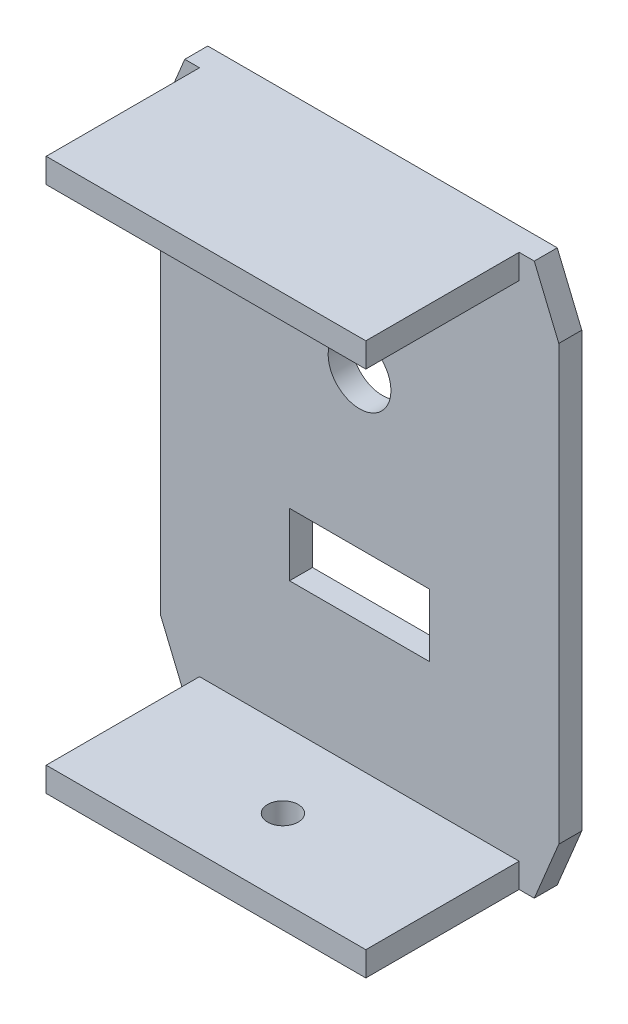
from build123d import *

# Parameters (mm, degrees)
BOSS_EXTRUDE1_DEPTH = 4.7625
SKETCH3_W           = 66.200858932
SKETCH3_H           = 5.079818348
BOSS_EXTRUDE2_DEPTH = 31.75
SKETCH4_W           = 28.999942
SKETCH4_H           = 12.9999994
CUT_EXTRUDE1_DEPTH  = 4.7625
SKETCH5_R           = 6.4999997
CUT_EXTRUDE2_DEPTH  = 4.7625
SKETCH6_R           = 3.175
CUT_EXTRUDE3_DEPTH  = 7.3025


with BuildPart() as part:
    # Sketch1 → Boss-Extrude1 (new body)
    with BuildSketch(Plane.XY):
        Polygon((30.222809818, 36.11360466), (25.142809818, 48.349181892), (-47.247190182, 48.349181892), (-52.327190182, 36.11360466), (-52.327190182, -53.715240876), (-47.247190182, -65.950818108), (25.142809818, -65.950818108), (30.222809818, -53.715240876), align=None)
    extrude(amount=BOSS_EXTRUDE1_DEPTH)

    # Sketch3 → Boss-Extrude2 (add)
    with BuildSketch(Plane.XY.offset(4.7625)):
        with Locations((-11.098760716, 45.809272718)):
            Rectangle(SKETCH3_W, SKETCH3_H)
        with Locations((-11.098760716, -63.410908934)):
            Rectangle(SKETCH3_W, SKETCH3_H)
    extrude(amount=BOSS_EXTRUDE2_DEPTH)

    # Sketch4 → Cut-Extrude1 (cut)
    with BuildSketch(Plane(origin=(0, 0, 0), x_dir=(-1, 0, 0), z_dir=(0, 0, -1))):
        with Locations((11.052190182, -27.850818108)):
            Rectangle(SKETCH4_W, SKETCH4_H)
    extrude(amount=-CUT_EXTRUDE1_DEPTH, mode=Mode.SUBTRACT)

    # Sketch5 → Cut-Extrude2 (cut)
    with BuildSketch(Plane(origin=(0, 0, 0), x_dir=(-1, 0, 0), z_dir=(0, 0, -1))):
        with Locations((11.052190182, 10.249181892)):
            Circle(SKETCH5_R)
    extrude(amount=-CUT_EXTRUDE2_DEPTH, mode=Mode.SUBTRACT)

    # Sketch6 → Cut-Extrude3 (cut)
    with BuildSketch(Plane.XZ.offset(65.950818108)):
        with Locations((-11.052190182, 20.6375)):
            Circle(SKETCH6_R)
    extrude(amount=-CUT_EXTRUDE3_DEPTH, mode=Mode.SUBTRACT)


solid = part.part
